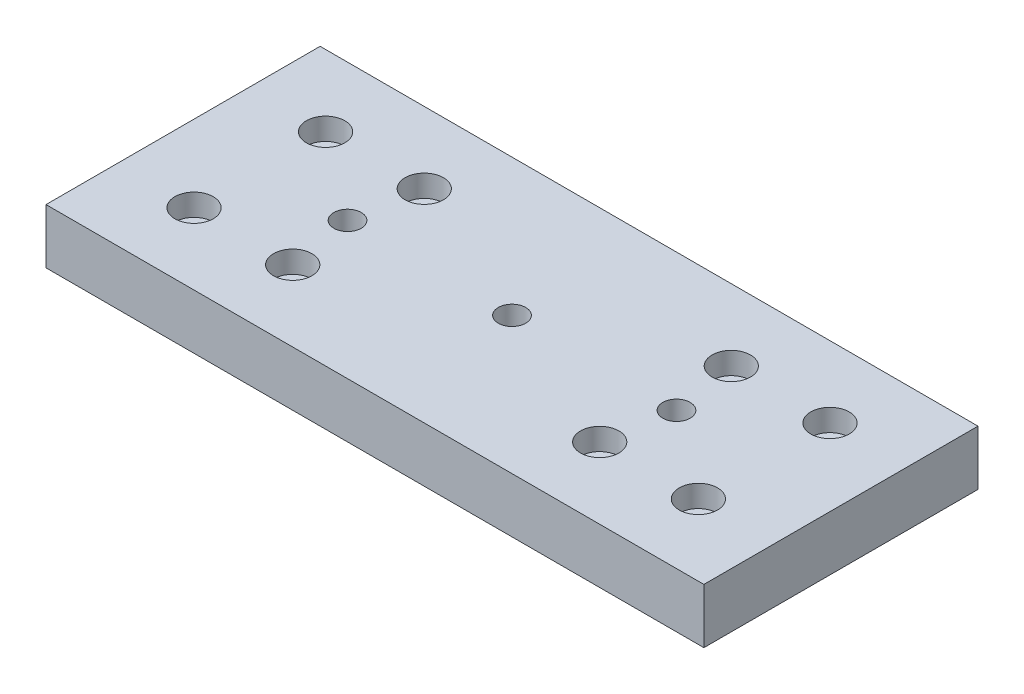
from build123d import *

# Parameters (mm, degrees)
SKETCH1_W                         = 120
SKETCH1_H                         = 50
BOSS_EXTRUDE1_DEPTH               = 10
SKETCH2_R                         = 1.5
LINEAR_BEARING_MOUNT_DEPTH        = 11
SKETCH3_R                         = 2.5
SURFACE_PROFILE_MOUNT_DEPTH       = 11
SKETCH4_R                         = 4.25
SURF_PROF_MOUNT_COUNTERSINK_DEPTH = 5
SKETCH5_R                         = 3.5
CUT_EXTRUDE1_DEPTH                = 4


with BuildPart() as part:
    # Sketch1 → Boss-Extrude1 (new body)
    with BuildSketch(Plane(origin=(0, 0, 0), x_dir=(1, 0, 0), z_dir=(0, 1, 0))):
        Rectangle(SKETCH1_W, SKETCH1_H)
    extrude(amount=BOSS_EXTRUDE1_DEPTH)

    # Sketch2 → Linear_bearing_mount (cut, through all)
    with BuildSketch(Plane(origin=(0, 10, 0), x_dir=(1, 0, 0), z_dir=(0, 1, 0))):
        with Locations((-28, -12)):
            Circle(SKETCH2_R)
        with Locations((-46, -12)):
            Circle(SKETCH2_R)
        with Locations((28, -12)):
            Circle(SKETCH2_R)
        with Locations((46, -12)):
            Circle(SKETCH2_R)
        with Locations((46, 12)):
            Circle(SKETCH2_R)
        with Locations((28, 12)):
            Circle(SKETCH2_R)
        with Locations((-46, 12)):
            Circle(SKETCH2_R)
        with Locations((-28, 12)):
            Circle(SKETCH2_R)
    extrude(amount=-LINEAR_BEARING_MOUNT_DEPTH, mode=Mode.SUBTRACT)

    # Sketch3 → Surface_profile_mount (cut, through all)
    with BuildSketch(Plane.XZ):
        Circle(SKETCH3_R)
        with Locations((30, 0)):
            Circle(SKETCH3_R)
        with Locations((-30, 0)):
            Circle(SKETCH3_R)
    extrude(amount=-SURFACE_PROFILE_MOUNT_DEPTH, mode=Mode.SUBTRACT)

    # Sketch4 → Surf.prof.mount_countersink (cut)
    with BuildSketch(Plane.XZ):
        with Locations((30, 0)):
            Circle(SKETCH4_R)
        Circle(SKETCH4_R)
        with Locations((-30, 0)):
            Circle(SKETCH4_R)
    extrude(amount=-SURF_PROF_MOUNT_COUNTERSINK_DEPTH, mode=Mode.SUBTRACT)

    # Sketch5 → Cut-Extrude1 (cut)
    with BuildSketch(Plane(origin=(0, 10, 0), x_dir=(1, 0, 0), z_dir=(0, 1, 0))):
        with Locations((-46, 12)):
            Circle(SKETCH5_R)
        with Locations((-28, 12)):
            Circle(SKETCH5_R)
        with Locations((-28, -12)):
            Circle(SKETCH5_R)
        with Locations((-46, -12)):
            Circle(SKETCH5_R)
        with Locations((46, -12)):
            Circle(SKETCH5_R)
        with Locations((28, -12)):
            Circle(SKETCH5_R)
        with Locations((28, 12)):
            Circle(SKETCH5_R)
        with Locations((46, 12)):
            Circle(SKETCH5_R)
    extrude(amount=-CUT_EXTRUDE1_DEPTH, mode=Mode.SUBTRACT)


solid = part.part
